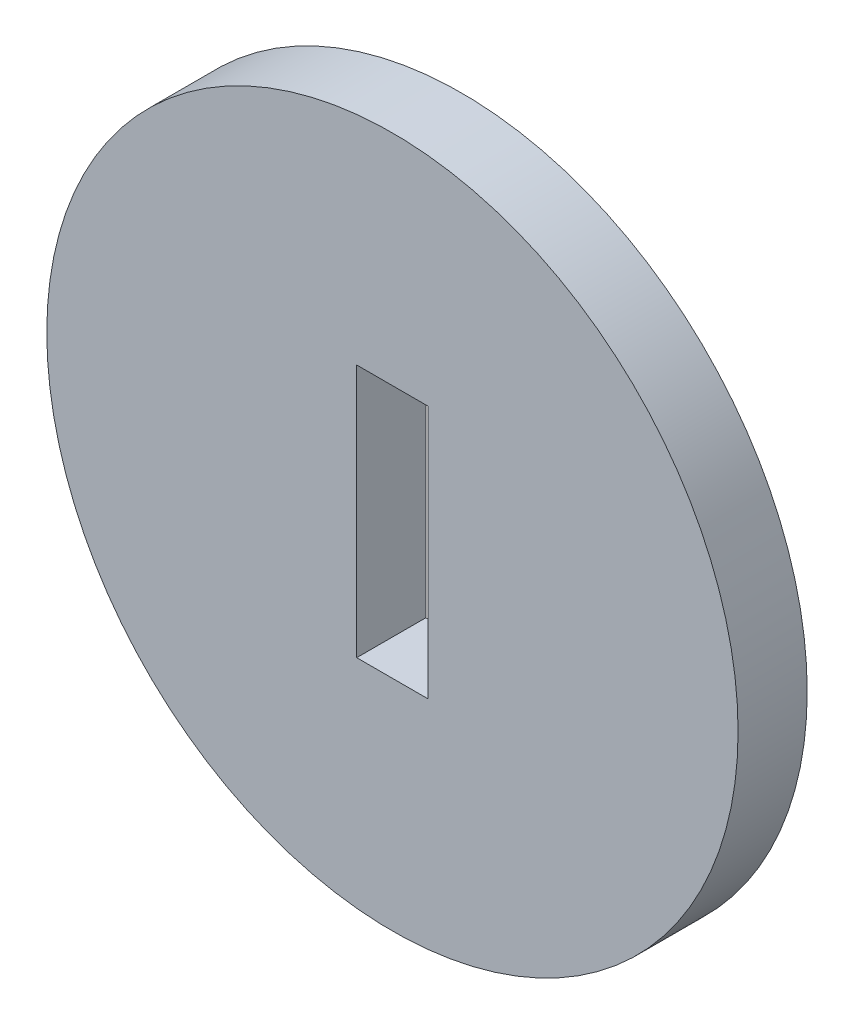
from build123d import *

# Parameters (mm, degrees)
SKETCH1_R           = 15
BOSS_EXTRUDE1_DEPTH = 3
SKETCH3_W           = 3.1
SKETCH3_H           = 11
CUT_EXTRUDE1_DEPTH  = 3


with BuildPart() as part:
    # Sketch1 → Boss-Extrude1 (new body)
    with BuildSketch(Plane.XY):
        Circle(SKETCH1_R)
    extrude(amount=BOSS_EXTRUDE1_DEPTH)

    # Sketch3 → Cut-Extrude1 (cut)
    with BuildSketch(Plane.XY):
        Rectangle(SKETCH3_W, SKETCH3_H)
    extrude(amount=CUT_EXTRUDE1_DEPTH, mode=Mode.SUBTRACT)


solid = part.part
